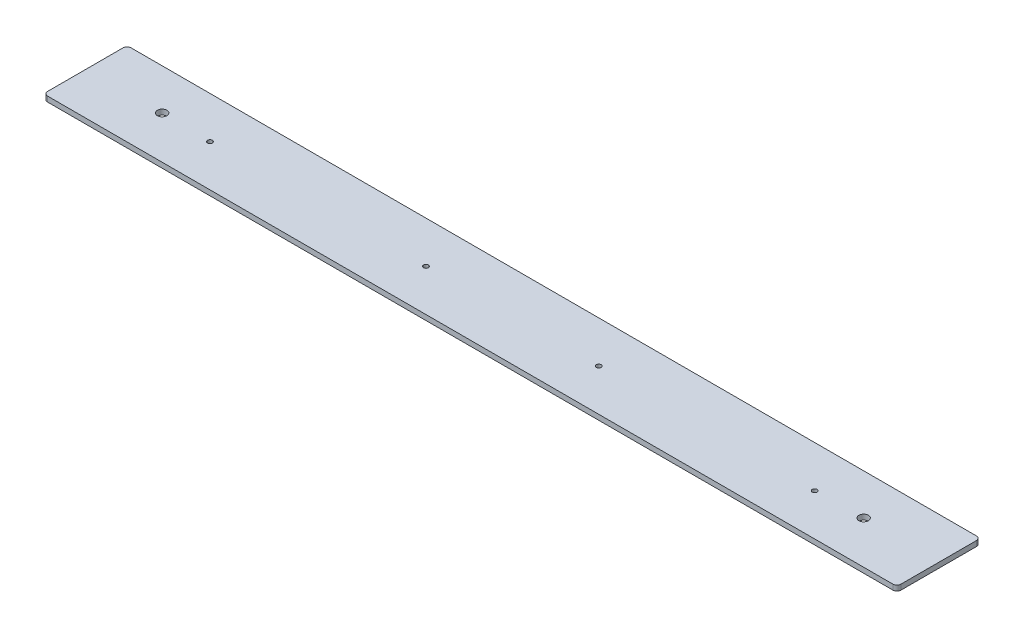
from build123d import *

# Parameters (mm, degrees)
SKETCH1_W                  = 519.1125
SKETCH1_H                  = 50.8
BOSS_EXTRUDE1_DEPTH        = 3.175
FILLET1_R                  = 2.54
F_4_CLEARANCE_HOLE1_D      = 2.9464
F_1_0_228_DIAMETER_HOLE1_D = 5.7912


with BuildPart() as part:
    # Sketch1 → Boss-Extrude1 (new body)
    with BuildSketch(Plane(origin=(0, 0, 0), x_dir=(1, 0, 0), z_dir=(0, 1, 0))):
        Rectangle(SKETCH1_W, SKETCH1_H)
    extrude(amount=BOSS_EXTRUDE1_DEPTH)

    # Fillet1
    fillet1_edges = [part.edges().sort_by_distance(p)[0] for p in [
        (259.55625, 1.5875, 25.4),
        (-259.55625, 1.5875, 25.4),
        (-259.55625, 1.5875, -25.4),
        (259.55625, 1.5875, -25.4),
    ]]
    fillet(fillet1_edges, radius=FILLET1_R)

    # #4 Clearance Hole1 (through all)
    with Locations(Plane(origin=(0, 3.175, 0), x_dir=(1, 0, 0), z_dir=(0, 1, 0))):
        with Locations((184.1103125, 0), (52.7446875, 0), (-52.3478125, 0), (-183.7134375, 0)):
            Hole(F_4_CLEARANCE_HOLE1_D / 2)

    # #1 (0.228) Diameter Hole1 (through all)
    with Locations(Plane(origin=(0, 0, 0), x_dir=(-1, 0, 0), z_dir=(0, -1, 0))):
        with Locations((-213.36, 0.5444109), (213.36, 0.5444109)):
            Hole(F_1_0_228_DIAMETER_HOLE1_D / 2)


solid = part.part
